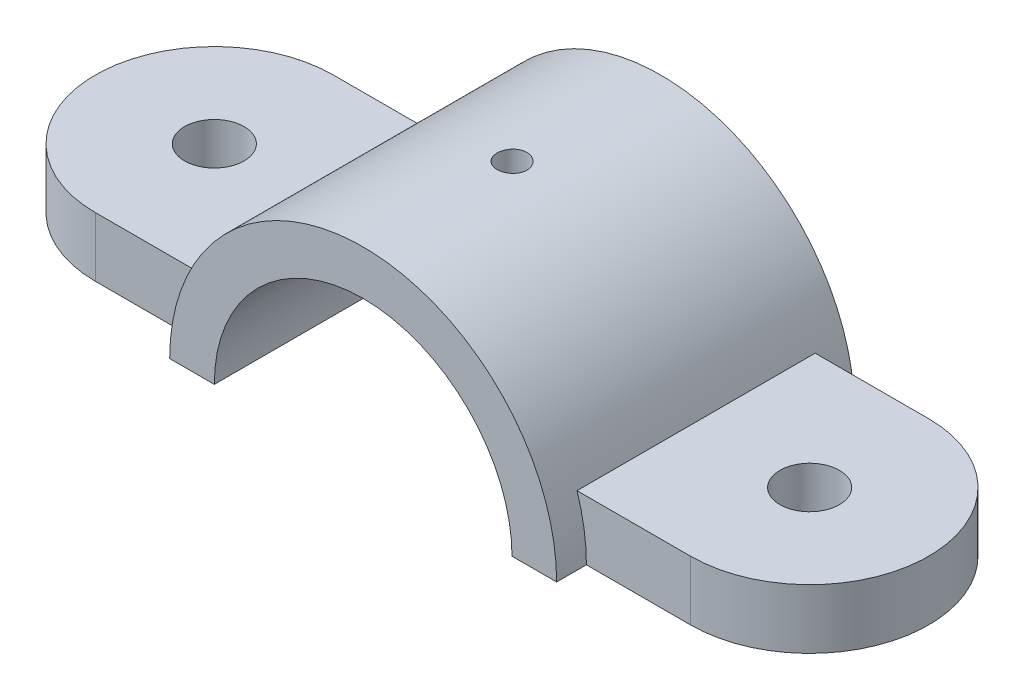
from build123d import *

# Parameters (mm, degrees)
SKETCH5_R           = 6.35
BOSS_EXTRUDE2_DEPTH = 12.7
BOSS_EXTRUDE3_DEPTH = 31.75
CUT_EXTRUDE1_DEPTH  = 63.5
SKETCH10_R          = 3.175
CUT_EXTRUDE2_DEPTH  = 63.5


with BuildPart() as part:
    # Sketch5 → Boss-Extrude2 (new body)
    with BuildSketch(Plane(origin=(0, 0, 0), x_dir=(1, 0, 0), z_dir=(0, 1, 0))):
        with BuildLine():
            Line((-63.5, 25.4), (63.5, 25.4))
            ThreePointArc((63.5, 25.4), (88.9, 0), (63.5, -25.4))
            Line((63.5, -25.4), (-63.5, -25.4))
            ThreePointArc((-63.5, -25.4), (-88.9, 0), (-63.5, 25.4))
        make_face()
        with Locations((-63.5, 0)):
            Circle(SKETCH5_R, mode=Mode.SUBTRACT)
        with Locations((63.5, 0)):
            Circle(SKETCH5_R, mode=Mode.SUBTRACT)
    extrude(amount=BOSS_EXTRUDE2_DEPTH)

    # Sketch6 → Boss-Extrude3 (add, symmetric)
    with BuildSketch(Plane.XY):
        with BuildLine():
            Line((-41.275, 0), (41.275, 0))
            ThreePointArc((41.275, 0), (0, 41.275), (-41.275, 0))
        make_face()
    extrude(amount=BOSS_EXTRUDE3_DEPTH, both=True)

    # Sketch7 → Cut-Extrude1 (cut)
    with BuildSketch(Plane.XY.offset(31.75)):
        with BuildLine():
            Line((-31.75, 0), (31.75, 0))
            ThreePointArc((31.75, 0), (0, 31.75), (-31.75, 0))
        make_face()
    extrude(amount=-CUT_EXTRUDE1_DEPTH, mode=Mode.SUBTRACT)

    # Sketch10 → Cut-Extrude2 (cut)
    with BuildSketch(Plane(origin=(0, 41.275, 0), x_dir=(1, 0, 0), z_dir=(0, 1, 0))):
        Circle(SKETCH10_R)
    extrude(amount=-CUT_EXTRUDE2_DEPTH, mode=Mode.SUBTRACT)


solid = part.part
